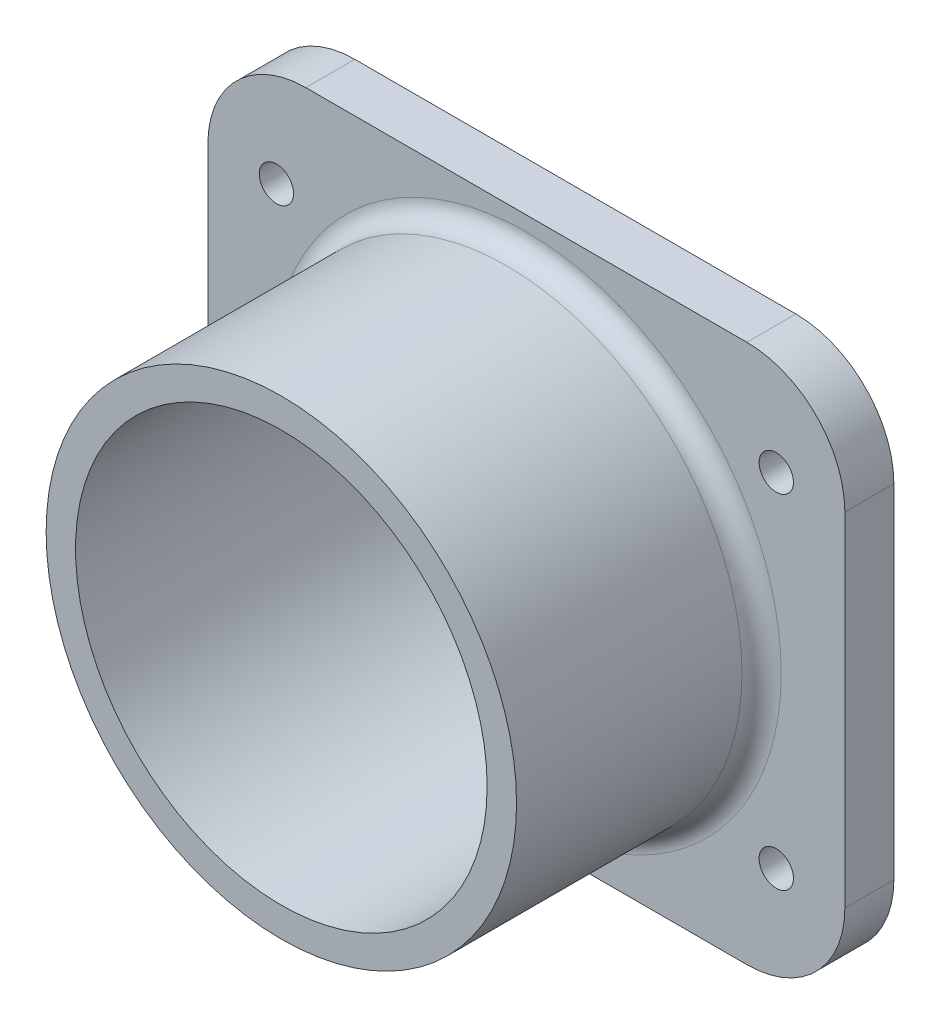
from build123d import *

# Parameters (mm, degrees)
SKETCH_1_R          = 27.5
EXTRUDE_1_DEPTH     = 5
SKETCH_2_R          = 24
EXTRUDE_2_DEPTH     = 25
SKETCH_4_W          = 65
SKETCH_4_H          = 55
EXTRUDE_3_DEPTH     = 5
SKETCH_5_R          = 21
CUT_EXTRUDE_1_DEPTH = 59
FILLET_1_R          = 10
SKETCH_6_R          = 1.75
CUT_EXTRUDE_2_DEPTH = 10
FILLET_2_R          = 2


with BuildPart() as part:
    # 草图1 → 凸台-拉伸1 (new body)
    with BuildSketch(Plane.XY):
        Circle(SKETCH_1_R)
    extrude(amount=EXTRUDE_1_DEPTH)

    # 草图2 → 凸台-拉伸2 (add)
    with BuildSketch(Plane.XY.offset(5)):
        Circle(SKETCH_2_R)
    extrude(amount=EXTRUDE_2_DEPTH)

    # 草图4 → 凸台-拉伸3 (add)
    with BuildSketch(Plane(origin=(0, 0, 0), x_dir=(-1, 0, 0), z_dir=(0, 0, -1))):
        Rectangle(SKETCH_4_W, SKETCH_4_H)
    extrude(amount=-EXTRUDE_3_DEPTH)

    # 草图5 → 切除-拉伸1 (cut)
    with BuildSketch(Plane.XY.offset(30)):
        Circle(SKETCH_5_R)
    extrude(amount=-CUT_EXTRUDE_1_DEPTH, mode=Mode.SUBTRACT)

    # 圆角1
    fillet_1_edges = [part.edges().sort_by_distance(p)[0] for p in [
        (32.5, 27.5, 2.5),
        (-32.5, -27.5, 2.5),
        (32.5, -27.5, 2.5),
        (-32.5, 27.5, 2.5),
    ]]
    fillet(fillet_1_edges, radius=FILLET_1_R)

    # 草图6 → 切除-拉伸2 (cut)
    with BuildSketch(Plane.XY.offset(5)):
        with Locations((-25.5, -17.5)):
            Circle(SKETCH_6_R)
        with Locations((-25.5, 17.5)):
            Circle(SKETCH_6_R)
        with Locations((25.5, 17.5)):
            Circle(SKETCH_6_R)
        with Locations((25.5, -17.5)):
            Circle(SKETCH_6_R)
    extrude(amount=-CUT_EXTRUDE_2_DEPTH, mode=Mode.SUBTRACT)

    # 圆角2
    fillet_2_edges = [part.edges().sort_by_distance(p)[0] for p in [
        (-24, 0, 5),
    ]]
    fillet(fillet_2_edges, radius=FILLET_2_R)


solid = part.part
